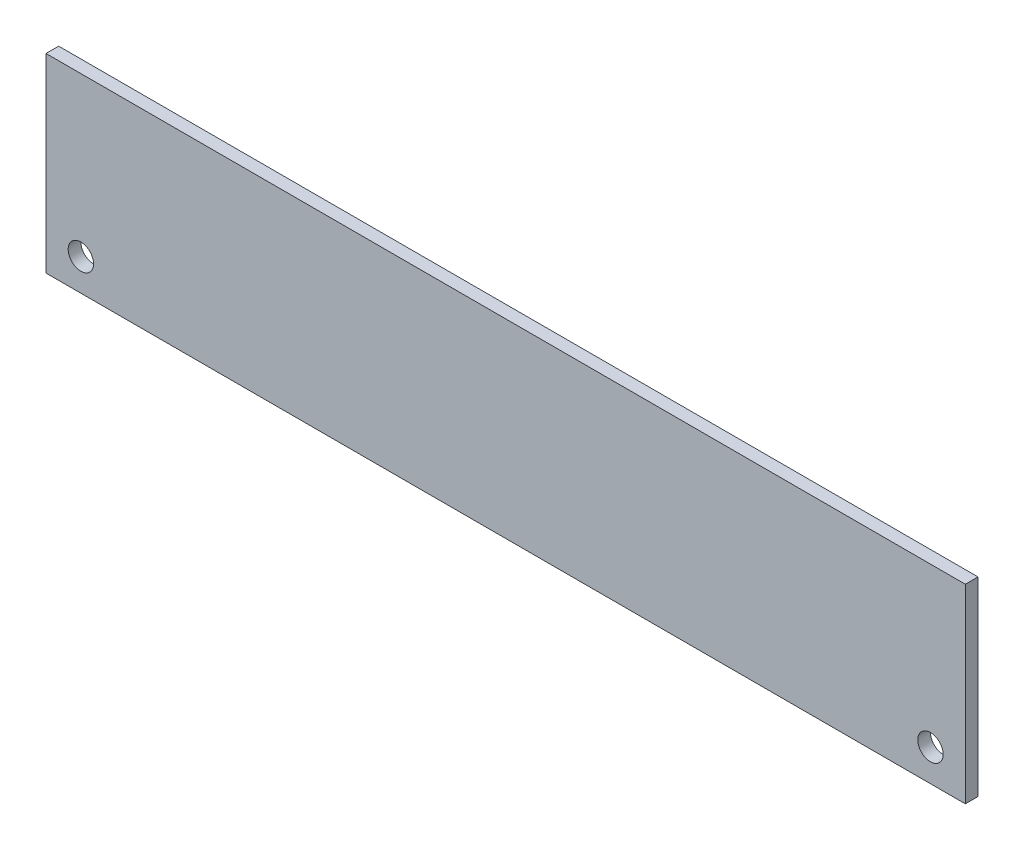
from build123d import *

# Parameters (mm, degrees)
ESQUISSE1_W      = 145
ESQUISSE1_H      = 30
ESQUISSE1_R      = 2
EXTRUSION1_DEPTH = 2


with BuildPart() as part:
    # Esquisse1 → Extrusion1 (new body)
    with BuildSketch(Plane.XY):
        with Locations((-72.5, 15)):
            Rectangle(ESQUISSE1_W, ESQUISSE1_H)
        with Locations((-5.5, 5)):
            Circle(ESQUISSE1_R, mode=Mode.SUBTRACT)
        with Locations((-139.5, 5)):
            Circle(ESQUISSE1_R, mode=Mode.SUBTRACT)
    extrude(amount=EXTRUSION1_DEPTH)


solid = part.part
